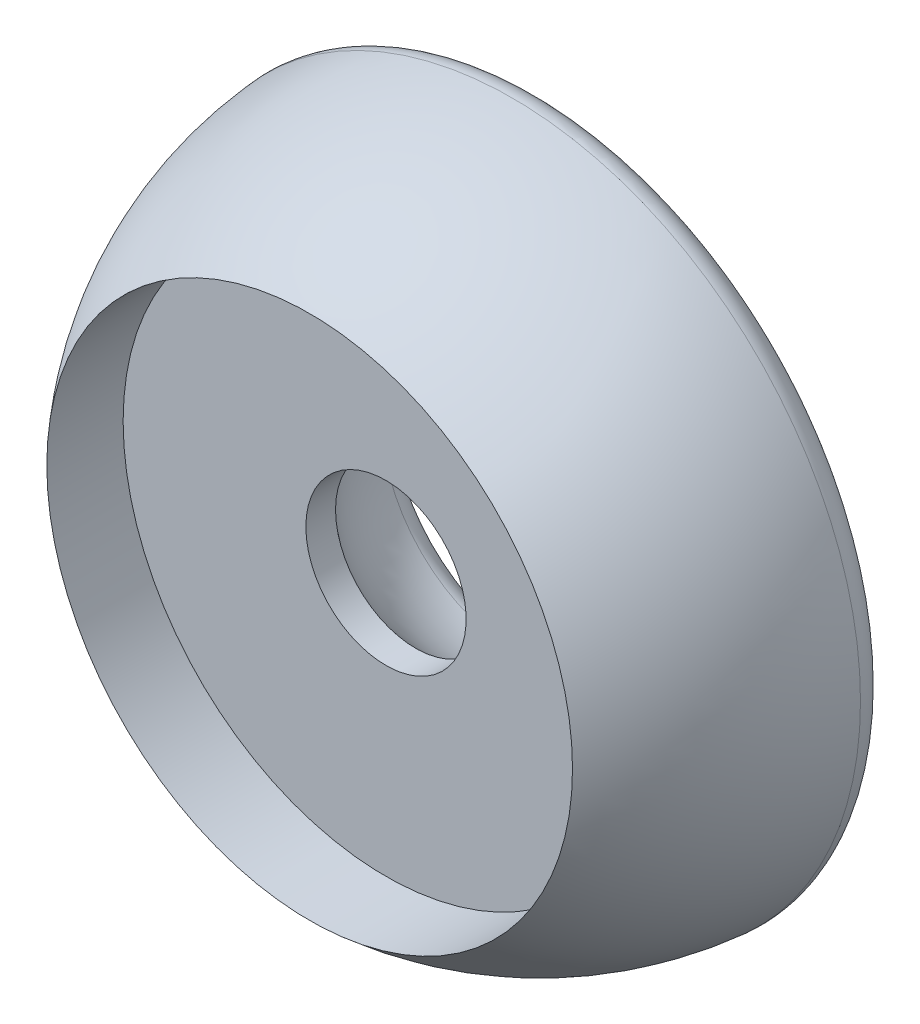
from build123d import *

# Parameters (mm, degrees)
BOTTOM_FILLET_R = 0.4


with BuildPart() as part:
    # Sketch2 → Main Body (revolve)
    with BuildSketch(Plane(origin=(0, 0, 0), x_dir=(1, 0, 0), z_dir=(0, 1, 0))):
        with BuildLine():
            Line((2.1, 0), (5.45, 0))
            ThreePointArc((5.45, 0), (5.101347861, -1.918006778), (4.1, -3.590612761))
            Line((4.1, -3.590612761), (4.1, -2.4))
            Line((4.1, -2.4), (1.25, -2.4))
            Line((1.25, -2.4), (1.25, -1.937095277))
            ThreePointArc((1.25, -1.937095277), (1.876107285, -1.16695398), (2.1, -0.2))
            Line((2.1, -0.2), (2.1, 0))
        make_face()
    revolve(axis=Axis((0, 0, 0), (0, 0, 1)))

    # Bottom Fillet
    bottom_fillet_edges = [part.edges().sort_by_distance(p)[0] for p in [
        (-5.45, 0, 0),
        (-2.1, 0, 0),
    ]]
    fillet(bottom_fillet_edges, radius=BOTTOM_FILLET_R)


solid = part.part
